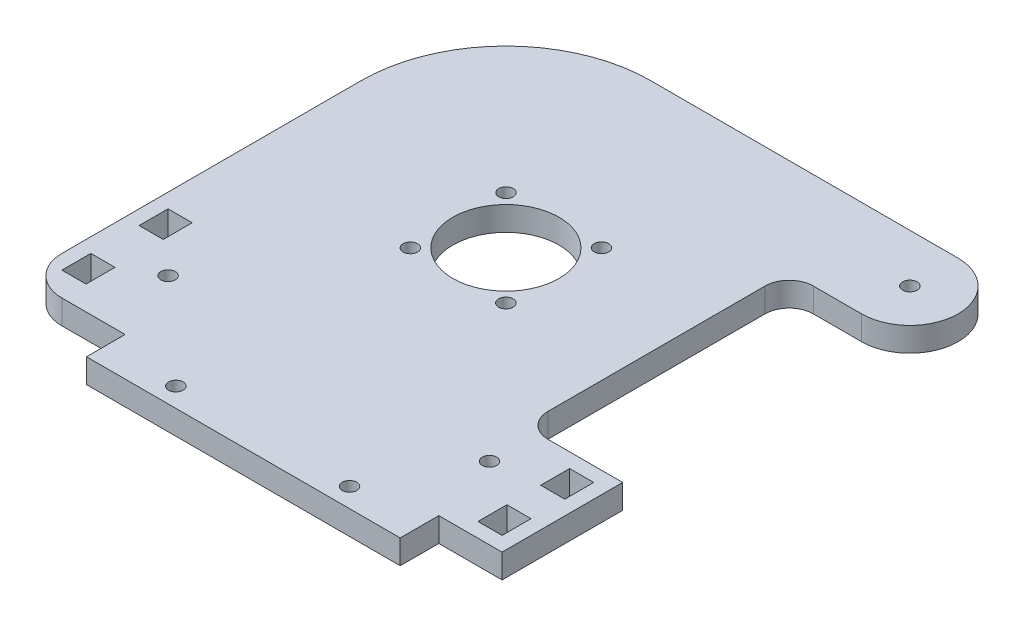
from build123d import *

# Parameters (mm, degrees)
SKETCH1_R           = 11
SKETCH1_R_2         = 1.5
SKETCH1_W           = 5
SKETCH1_H           = 6
BOSS_EXTRUDE1_DEPTH = 5


with BuildPart() as part:
    # Sketch1 → Boss-Extrude1 (new body)
    with BuildSketch(Plane(origin=(0, 0, 0), x_dir=(1, 0, 0), z_dir=(0, 1, 0))):
        with BuildLine():
            Line((48.7, 25.000004028), (38.700001305, 25.000004028))
            ThreePointArc((38.700001305, 25.000004028), (35.164467017, 23.535538857), (33.7, 20.000005334))
            Line((33.7, 20.000005334), (33.7, -25))
            ThreePointArc((33.7, -25), (35.164465799, -28.535533784), (38.699999411, -30))
            Line((38.699999411, -30), (54.2, -30))
            Line((54.2, -30), (54.2, -55))
            Line((54.2, -55), (41.099999997, -55))
            Line((41.099999997, -55), (41.099999997, -63))
            Line((41.099999997, -63), (-23.900000003, -63))
            Line((-23.900000003, -63), (-23.900000003, -55))
            Line((-23.900000003, -55), (-37.00036842, -55))
            ThreePointArc((-37.00036842, -55), (-42.656802211, -52.657122122), (-45.000000024, -47.000820858))
            Line((-45.000000024, -47.000820858), (-45.000000024, 15.001139744))
            ThreePointArc((-45.000000024, 15.001139744), (-36.213537283, 36.213537259), (-15.001139768, 45))
            Line((-15.001139768, 45), (48.7, 45))
            ThreePointArc((48.7, 45), (58.699997986, 35.000002014), (48.7, 25.000004028))
        make_face()
        Circle(SKETCH1_R, mode=Mode.SUBTRACT)
        with Locations((9.89288341, 9.906102051)):
            Circle(SKETCH1_R_2, mode=Mode.SUBTRACT)
        with Locations((9.89288341, -9.906102051)):
            Circle(SKETCH1_R_2, mode=Mode.SUBTRACT)
        with Locations((-9.89288341, -9.906102051)):
            Circle(SKETCH1_R_2, mode=Mode.SUBTRACT)
        with Locations((-9.89288341, 9.906102051)):
            Circle(SKETCH1_R_2, mode=Mode.SUBTRACT)
        with Locations((-9.400000003, -59)):
            Circle(SKETCH1_R_2, mode=Mode.SUBTRACT)
        with Locations((26.599999997, -59)):
            Circle(SKETCH1_R_2, mode=Mode.SUBTRACT)
        with Locations((48.7, 35.000002014)):
            Circle(SKETCH1_R_2, mode=Mode.SUBTRACT)
        with Locations((-30.000000024, -40)):
            Circle(SKETCH1_R_2, mode=Mode.SUBTRACT)
        with Locations((36.599999976, -40)):
            Circle(SKETCH1_R_2, mode=Mode.SUBTRACT)
        with Locations((-39.500000024, -31)):
            Rectangle(SKETCH1_W, SKETCH1_H, mode=Mode.SUBTRACT)
        with Locations((-39.500000024, -47)):
            Rectangle(SKETCH1_W, SKETCH1_H, mode=Mode.SUBTRACT)
        with Locations((48.7, -36)):
            Rectangle(SKETCH1_W, SKETCH1_H, mode=Mode.SUBTRACT)
        with Locations((48.7, -49)):
            Rectangle(SKETCH1_W, SKETCH1_H, mode=Mode.SUBTRACT)
    extrude(amount=BOSS_EXTRUDE1_DEPTH)


solid = part.part
